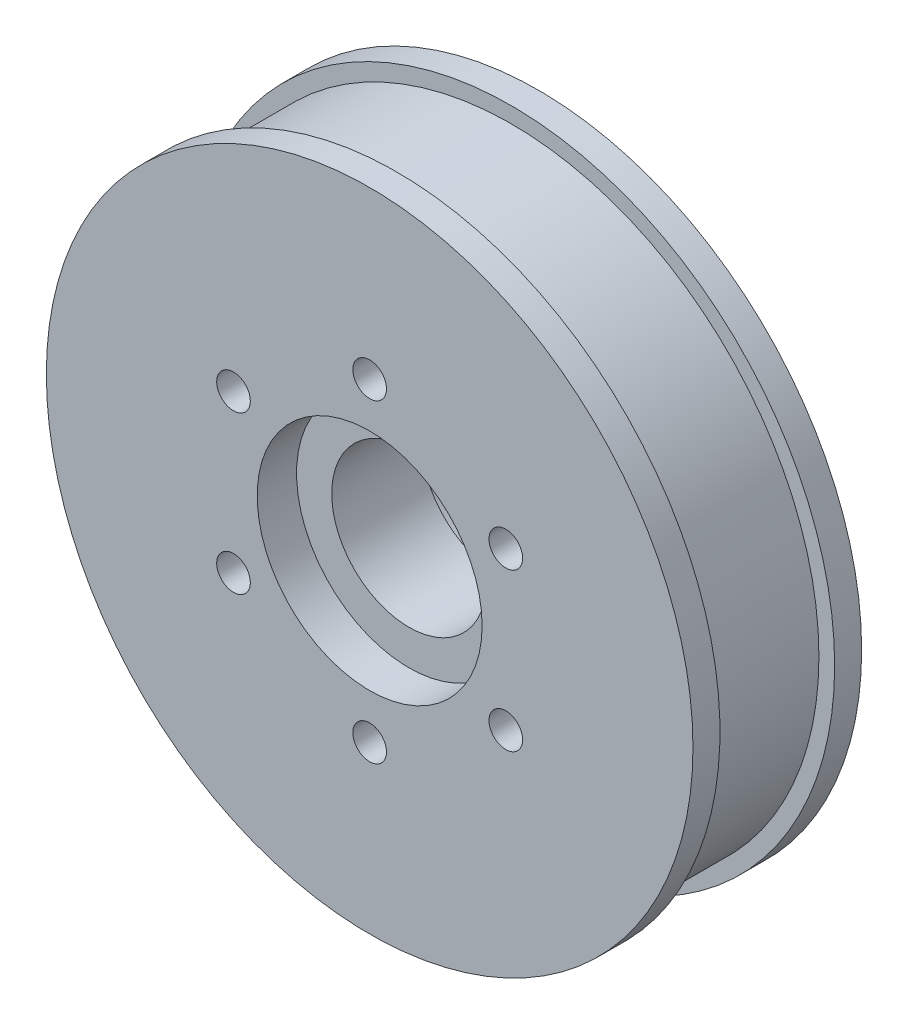
from build123d import *

# Parameters (mm, degrees)
SKETCH1_R             = 36.5125
BOSS_EXTRUDE1_DEPTH   = 19.05
SKETCH2_R             = 8.73125
CUT_EXTRUDE1_DEPTH    = 20.05
SKETCH3_R             = 12.7
CUT_EXTRUDE2_DEPTH    = 4.445
SKETCH4_R             = 12.7
CUT_EXTRUDE3_DEPTH    = 4.445
F_6_CLEARANCE_HOLE1_D = 3.7973


with BuildPart() as part:
    # Sketch1 → Boss-Extrude1 (new body)
    with BuildSketch(Plane.XY):
        Circle(SKETCH1_R)
    extrude(amount=BOSS_EXTRUDE1_DEPTH)

    # Sketch2 → Cut-Extrude1 (cut, through all)
    with BuildSketch(Plane.XY.offset(19.05)):
        Circle(SKETCH2_R)
    extrude(amount=-CUT_EXTRUDE1_DEPTH, mode=Mode.SUBTRACT)

    # Sketch3 → Cut-Extrude2 (cut)
    with BuildSketch(Plane.XY.offset(19.05)):
        Circle(SKETCH3_R)
    extrude(amount=-CUT_EXTRUDE2_DEPTH, mode=Mode.SUBTRACT)

    # Sketch4 → Cut-Extrude3 (cut)
    with BuildSketch(Plane(origin=(0, 0, 0), x_dir=(-1, 0, 0), z_dir=(0, 0, -1))):
        Circle(SKETCH4_R)
    extrude(amount=-CUT_EXTRUDE3_DEPTH, mode=Mode.SUBTRACT)

    # #6 Clearance Hole1 (through all)
    with Locations(Plane(origin=(-8.170302988, -47.003517203, 19.05), x_dir=(1, 0, 0), z_dir=(0, 0, 1))):
        with Locations((8.170302988, 64.758117203), (-7.205631646, 55.880817203), (-7.205631646, 38.126217203), (8.170302988, 29.248917203), (23.546237622, 38.126217203), (23.546237622, 55.880817203)):
            Hole(F_6_CLEARANCE_HOLE1_D / 2)

    # Sketch10 → Cut-Revolve1 (revolve, cut)
    with BuildSketch(Plane(origin=(0, 0, 0), x_dir=(0, 0, -1), z_dir=(1, 0, 0))):
        Polygon((-16.002, 36.5125), (-16.002, 34.7345), (-3.048, 34.7345), (-3.048, 36.5125), (-3.048, 51.152208686), (-16.002, 51.152208686), align=None)
    revolve(axis=Axis((0, 0, 19.05), (0, 0, -1)), mode=Mode.SUBTRACT)


solid = part.part
